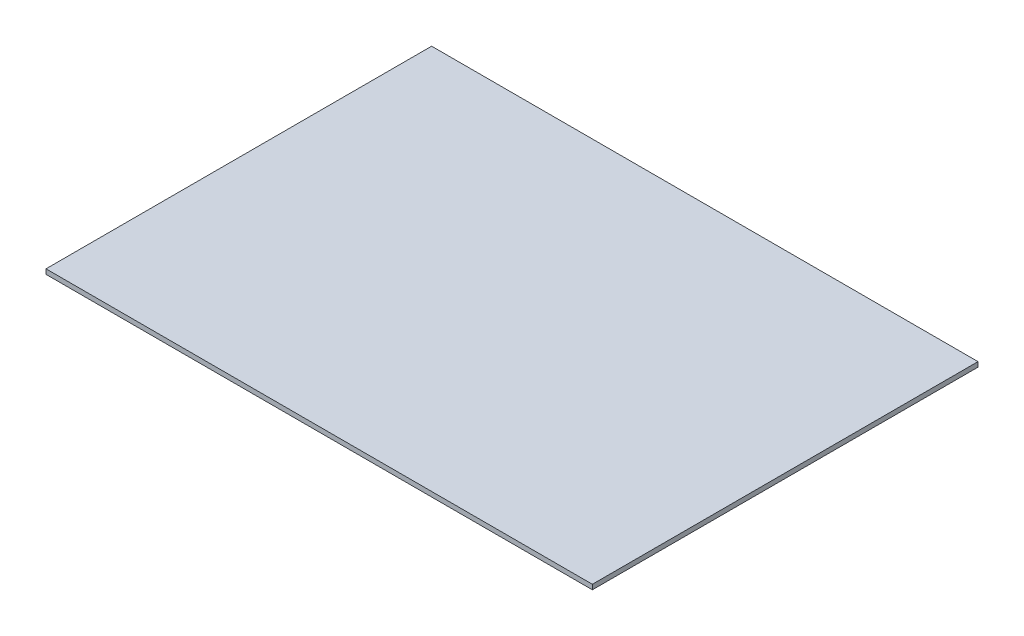
from build123d import *

# Parameters (mm, degrees)
SKETCH1_W      = 287.483745419
SKETCH1_H      = 202.903923977
EXTRUDE1_DEPTH = 2.54


with BuildPart() as part:
    # Sketch1 → Extrude1 (new body)
    with BuildSketch(Plane(origin=(0, 0, 0), x_dir=(1, 0, 0), z_dir=(0, 1, 0))):
        with Locations((27.783562745, 15.176473841)):
            Rectangle(SKETCH1_W, SKETCH1_H)
    extrude(amount=EXTRUDE1_DEPTH)


solid = part.part
